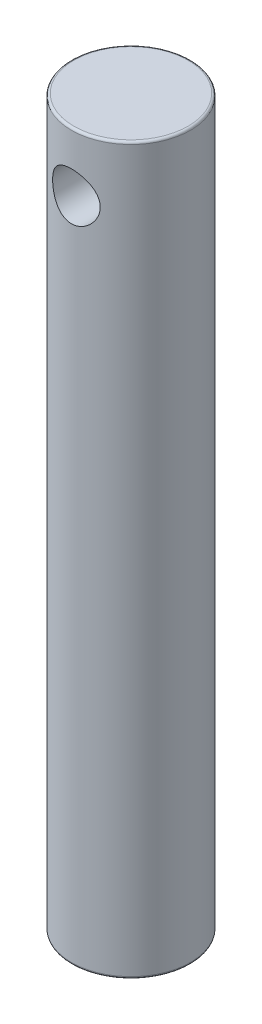
from build123d import *

# Parameters (mm, degrees)
SWEEP1_PROFILE_R        = 12.5
SKETCH6_R               = 5
CUT_EXTRUDE1_DEPTH      = 13.5
CUT_EXTRUDE1_DEPTH_BACK = 13.5
FILLET1_R               = 0.5


with BuildPart() as part:
    # Sweep1: sweep along a path in Sketch1
    with BuildLine(Plane.XY) as sweep1_path:
        Line((0, 0), (0, 152.4))
    # Sweep1 profile (on start of the path) → Sweep1 (sweep)
    with BuildSketch(Plane.ZX):
        Circle(SWEEP1_PROFILE_R)
    sweep(path=sweep1_path.line)

    # Sketch6 → Cut-Extrude1 (cut, two sides)
    with BuildSketch(Plane.XY) as cut_extrude1_sk:
        with Locations((0, 139.9)):
            Circle(SKETCH6_R)
    extrude(amount=CUT_EXTRUDE1_DEPTH, mode=Mode.SUBTRACT)
    extrude(cut_extrude1_sk.sketch, amount=-CUT_EXTRUDE1_DEPTH_BACK, mode=Mode.SUBTRACT)

    # Fillet1
    fillet1_edges = [part.edges().sort_by_distance(p)[0] for p in [
        (0, 0, -12.5),
        (0, 152.4, -12.5),
    ]]
    fillet(fillet1_edges, radius=FILLET1_R)


solid = part.part
